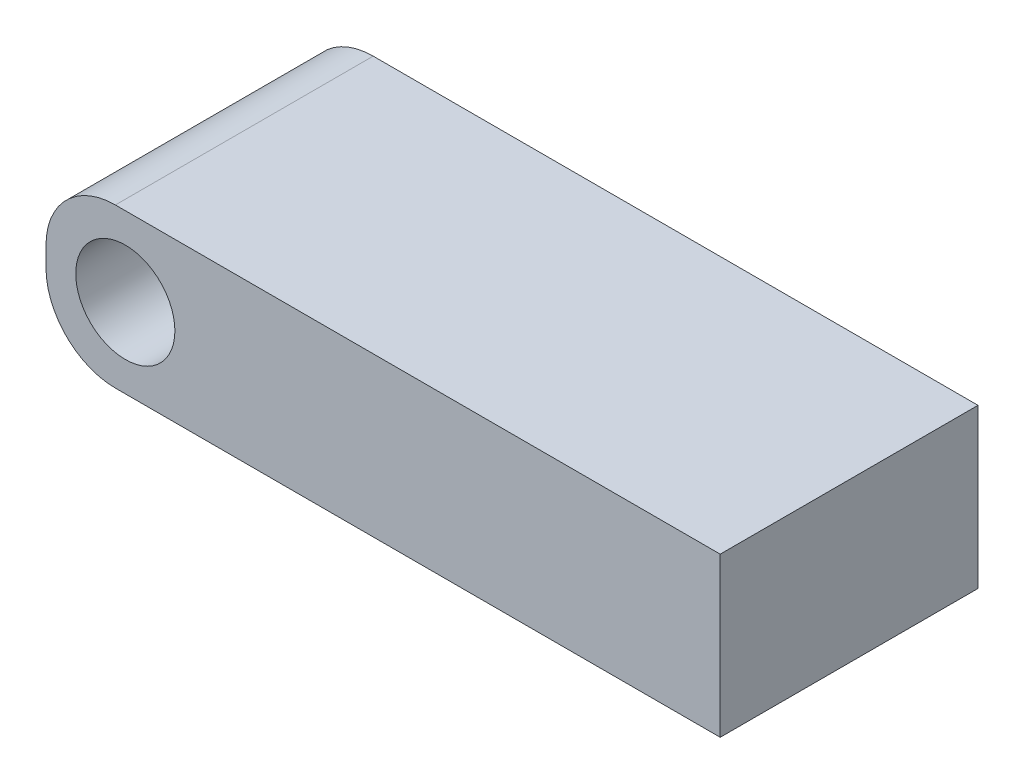
from build123d import *

# Parameters (mm, degrees)
SKETCH1_R           = 2.5
BOSS_EXTRUDE1_DEPTH = 6.5


with BuildPart() as part:
    # Sketch1 → Boss-Extrude1 (new body, symmetric)
    with BuildSketch(Plane.XY):
        with BuildLine():
            Line((-19.5, 34.428638458), (11, 34.428638458))
            Line((11, 34.428638458), (11, 26.428638458))
            Line((11, 26.428638458), (-19.5, 26.428638458))
            ThreePointArc((-19.5, 26.428638458), (-21.974873734, 27.453764724), (-23, 29.928638458))
            Line((-23, 29.928638458), (-23, 30.928638458))
            ThreePointArc((-23, 30.928638458), (-21.974873734, 33.403512192), (-19.5, 34.428638458))
        make_face()
        with Locations((-19, 30.428638458)):
            Circle(SKETCH1_R, mode=Mode.SUBTRACT)
    extrude(amount=BOSS_EXTRUDE1_DEPTH, both=True)


solid = part.part
